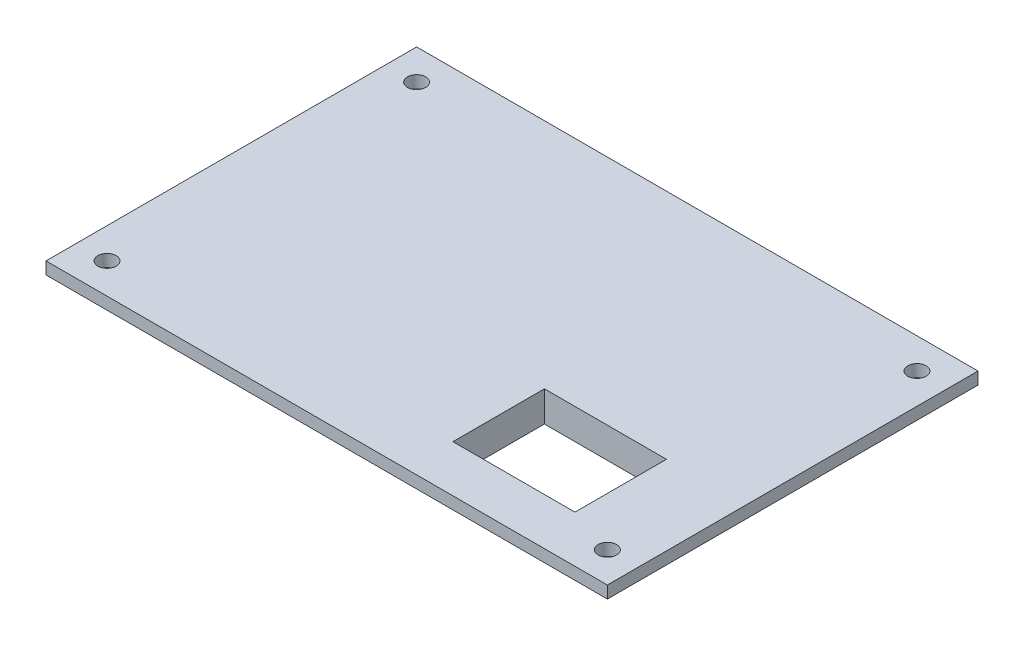
from build123d import *

# Parameters (mm, degrees)
SKETCH_1_W          = 92
SKETCH_1_H          = 60.74
EXTRUDE_1_DEPTH     = 2
SKETCH_2_R          = 1.5
CUT_EXTRUDE_1_DEPTH = 10
SKETCH_3_W          = 20
SKETCH_3_H          = 15
CUT_EXTRUDE_2_DEPTH = 10
SKETCH_4_W          = 24
SKETCH_4_H          = 19
SKETCH_4_W_2        = 20
SKETCH_4_H_2        = 15
EXTRUDE_2_DEPTH     = 3


with BuildPart() as part:
    # Эскиз1 → Бобышка-Вытянуть1 (new body)
    with BuildSketch(Plane(origin=(0, 0, 0), x_dir=(1, 0, 0), z_dir=(0, 1, 0))):
        Rectangle(SKETCH_1_W, SKETCH_1_H)
    extrude(amount=EXTRUDE_1_DEPTH)

    # Эскиз2 → Вырез-Вытянуть1 (cut)
    with BuildSketch(Plane(origin=(0, 2, 0), x_dir=(1, 0, 0), z_dir=(0, 1, 0))):
        with Locations((-41, 25.37)):
            Circle(SKETCH_2_R)
        with Locations((41, 25.37)):
            Circle(SKETCH_2_R)
        with Locations((41, -25.37)):
            Circle(SKETCH_2_R)
        with Locations((-41, -25.37)):
            Circle(SKETCH_2_R)
    extrude(amount=-CUT_EXTRUDE_1_DEPTH, mode=Mode.SUBTRACT)

    # Эскиз3 → Вырез-Вытянуть2 (cut)
    with BuildSketch(Plane(origin=(0, 2, 0), x_dir=(1, 0, 0), z_dir=(0, 1, 0))):
        with Locations((23, -15.185)):
            Rectangle(SKETCH_3_W, SKETCH_3_H)
    extrude(amount=-CUT_EXTRUDE_2_DEPTH, mode=Mode.SUBTRACT)

    # Эскиз4 → Бобышка-Вытянуть2 (add)
    with BuildSketch(Plane.XZ):
        with Locations((23, 15.185)):
            Rectangle(SKETCH_4_W, SKETCH_4_H)
        with Locations((23, 15.185)):
            Rectangle(SKETCH_4_W_2, SKETCH_4_H_2, mode=Mode.SUBTRACT)
    extrude(amount=EXTRUDE_2_DEPTH)


solid = part.part
